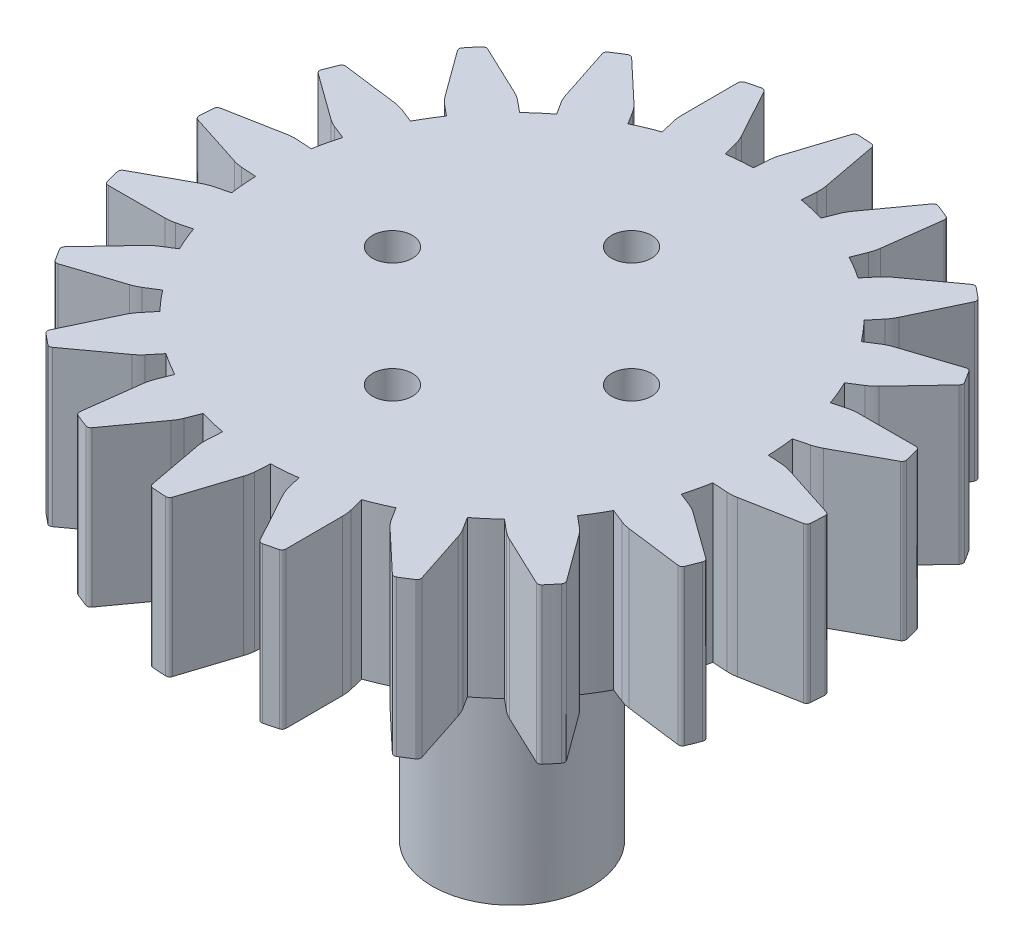
from build123d import *

# Parameters (mm, degrees)
SKETCH1_R           = 1.934028354
BOSS_EXTRUDE1_DEPTH = 7.8
SKETCH4_R           = 1
CUT_EXTRUDE1_DEPTH  = 10
SKETCH5_R           = 4
BOSS_EXTRUDE2_DEPTH = 15
SKETCH6_R           = 1.934028354
BOSS_EXTRUDE3_DEPTH = 20


with BuildPart() as part:
    # Sketch1 → Boss-Extrude1 (new body)
    with BuildSketch(Plane(origin=(0, 0, 0), x_dir=(1, 0, 0), z_dir=(0, 1, 0))):
        with BuildLine():
            Line((2.067271212, 12.648848174), (2.11435326, 13.397195901))
            ThreePointArc((2.11435326, 13.397195901), (2.11450544, 13.645915294), (2.083785622, 13.89273031))
            Line((2.083785622, 13.89273031), (1.557427029, 16.689164762))
            ThreePointArc((1.557427029, 16.689164762), (1.494636288, 16.800859841), (1.376943076, 16.8515232))
            ThreePointArc((1.376943076, 16.8515232), (1.030673751, 16.876365781), (0.684021261, 16.895118145))
            ThreePointArc((0.684021261, 16.895118145), (0.560906292, 16.859605153), (0.484611569, 16.756660589))
            Line((0.484611569, 16.756660589), (-0.388082701, 14.048247083))
            ThreePointArc((-0.388082701, 14.048247083), (-0.448161241, 13.822106517), (-0.481417178, 13.590496869))
            Line((-0.481417178, 13.590496869), (-0.528499226, 12.842149141))
            ThreePointArc((-0.528499226, 12.842149141), (-1.18702877, 12.804993072), (-1.842681652, 12.733152752))
            Line((-1.842681652, 12.733152752), (-2.029156128, 13.459422888))
            ThreePointArc((-2.029156128, 13.459422888), (-2.105869915, 13.696016113), (-2.211356233, 13.921258197))
            Line((-2.211356233, 13.921258197), (-3.576098772, 16.418171654))
            ThreePointArc((-3.576098772, 16.418171654), (-3.670331994, 16.504996582), (-3.797920728, 16.516811096))
            ThreePointArc((-3.797920728, 16.516811096), (-4.134919207, 16.433434689), (-4.470400115, 16.344147737))
            ThreePointArc((-4.470400115, 16.344147737), (-4.57651529, 16.272328257), (-4.617264264, 16.150845792))
            Line((-4.617264264, 16.150845792), (-4.610300035, 13.305314118))
            ThreePointArc((-4.610300035, 13.305314118), (-4.597556844, 13.071676369), (-4.557613802, 12.841125854))
            Line((-4.557613802, 12.841125854), (-4.371139325, 12.114855719))
            ThreePointArc((-4.371139325, 12.114855719), (-4.985956282, 11.876021376), (-5.587319349, 11.605089289))
            Line((-5.587319349, 11.605089289), (-5.989096929, 12.238189452))
            ThreePointArc((-5.989096929, 12.238189452), (-6.135167404, 12.439497117), (-6.305094485, 12.621118003))
            Line((-6.305094485, 12.621118003), (-8.374630462, 14.57409518))
            ThreePointArc((-8.374630462, 14.57409518), (-8.491081959, 14.627550926), (-8.616076943, 14.59936011))
            ThreePointArc((-8.616076943, 14.59936011), (-8.910816815, 14.415926177), (-9.202286933, 14.227339938))
            ThreePointArc((-9.202286933, 14.227339938), (-9.281015022, 14.126244161), (-9.282229453, 13.998115346))
            Line((-9.282229453, 13.998115346), (-8.396288432, 11.29400597))
            ThreePointArc((-8.396288432, 11.29400597), (-8.311970902, 11.075741129), (-8.202738785, 10.868817638))
            Line((-8.202738785, 10.868817638), (-7.800961204, 10.235717476))
            ThreePointArc((-7.800961204, 10.235717476), (-8.311883007, 9.81858363), (-8.800090651, 9.375080496))
            Line((-8.800090651, 9.375080496), (-9.377842546, 9.853038431))
            ThreePointArc((-9.377842546, 9.853038431), (-9.578971312, 9.999355138), (-9.796705511, 10.11957651))
            Line((-9.796705511, 10.11957651), (-12.368454324, 11.337446393))
            ThreePointArc((-12.368454324, 11.337446393), (-12.495725014, 11.352300337), (-12.605890866, 11.286863703))
            ThreePointArc((-12.605890866, 11.286863703), (-12.829520939, 11.021328037), (-13.048449142, 10.751902645))
            ThreePointArc((-13.048449142, 10.751902645), (-13.092083691, 10.63142653), (-13.053644702, 10.509193506))
            Line((-13.053644702, 10.509193506), (-11.375448969, 8.211203494))
            ThreePointArc((-11.375448969, 8.211203494), (-11.227810688, 8.029676845), (-11.059981896, 7.866635491))
            Line((-11.059981896, 7.866635491), (-10.48223, 7.388677556))
            ThreePointArc((-10.48223, 7.388677556), (-10.839244063, 6.834076175), (-11.166507118, 6.26141517))
            Line((-11.166507118, 6.26141517), (-11.863678947, 6.537445024))
            ThreePointArc((-11.863678947, 6.537445024), (-12.10017812, 6.614448276), (-12.344406096, 6.661502027))
            Line((-12.344406096, 6.661502027), (-15.166627054, 7.025051026))
            ThreePointArc((-15.166627054, 7.025051026), (-15.292258793, 6.999849161), (-15.376811713, 6.903572103))
            ThreePointArc((-15.376811713, 6.903572103), (-15.507441518, 6.581927184), (-15.632397587, 6.258035874))
            ThreePointArc((-15.632397587, 6.258035874), (-15.636667342, 6.129972464), (-15.562337609, 6.02560025))
            Line((-15.562337609, 6.02560025), (-13.256160656, 4.358672877))
            ThreePointArc((-13.256160656, 4.358672877), (-13.059653487, 4.231653512), (-12.849656271, 4.128453919))
            Line((-12.849656271, 4.128453919), (-12.152484442, 3.852424065))
            ThreePointArc((-12.152484442, 3.852424065), (-12.32064374, 3.214643394), (-12.454927419, 2.568880568))
            Line((-12.454927419, 2.568880568), (-13.203275146, 2.615962617))
            ThreePointArc((-13.203275146, 2.615962617), (-13.451994539, 2.616114797), (-13.698809555, 2.585394979))
            Line((-13.698809555, 2.585394979), (-16.495244007, 2.059036386))
            ThreePointArc((-16.495244007, 2.059036386), (-16.606939087, 1.996245645), (-16.657602445, 1.878552433))
            ThreePointArc((-16.657602445, 1.878552433), (-16.682445026, 1.532283107), (-16.701197391, 1.185630617))
            ThreePointArc((-16.701197391, 1.185630617), (-16.665684399, 1.062515649), (-16.562739835, 0.986220926))
            Line((-16.562739835, 0.986220926), (-13.854326328, 0.113526656))
            ThreePointArc((-13.854326328, 0.113526656), (-13.628185762, 0.053448116), (-13.396576114, 0.020192179))
            Line((-13.396576114, 0.020192179), (-12.648228387, -0.026889869))
            ThreePointArc((-12.648228387, -0.026889869), (-12.611072317, -0.685419413), (-12.539231998, -1.341072295))
            Line((-12.539231998, -1.341072295), (-13.265502133, -1.527546772))
            ThreePointArc((-13.265502133, -1.527546772), (-13.502095359, -1.604260559), (-13.727337442, -1.709746877))
            Line((-13.727337442, -1.709746877), (-16.2242509, -3.074489416))
            ThreePointArc((-16.2242509, -3.074489416), (-16.311075827, -3.168722637), (-16.322890342, -3.296311372))
            ThreePointArc((-16.322890342, -3.296311372), (-16.239513934, -3.63330985), (-16.150226982, -3.968790759))
            ThreePointArc((-16.150226982, -3.968790759), (-16.078407502, -4.074905934), (-15.956925038, -4.115654907))
            Line((-15.956925038, -4.115654907), (-13.111393363, -4.108690679))
            ThreePointArc((-13.111393363, -4.108690679), (-12.877755614, -4.095947487), (-12.6472051, -4.056004446))
            Line((-12.6472051, -4.056004446), (-11.920934964, -3.869529969))
            ThreePointArc((-11.920934964, -3.869529969), (-11.682100622, -4.484346926), (-11.411168535, -5.085709992))
            Line((-11.411168535, -5.085709992), (-12.044268697, -5.487487573))
            ThreePointArc((-12.044268697, -5.487487573), (-12.245576362, -5.633558047), (-12.427197249, -5.803485129))
            Line((-12.427197249, -5.803485129), (-14.380174426, -7.873021105))
            ThreePointArc((-14.380174426, -7.873021105), (-14.433630172, -7.989472603), (-14.405439355, -8.114467586))
            ThreePointArc((-14.405439355, -8.114467586), (-14.222005423, -8.409207458), (-14.033419183, -8.700677577))
            ThreePointArc((-14.033419183, -8.700677577), (-13.932323406, -8.779405665), (-13.804194592, -8.780620096))
            Line((-13.804194592, -8.780620096), (-11.100085215, -7.894679076))
            ThreePointArc((-11.100085215, -7.894679076), (-10.881820375, -7.810361546), (-10.674896884, -7.701129428))
            Line((-10.674896884, -7.701129428), (-10.041796721, -7.299351848))
            ThreePointArc((-10.041796721, -7.299351848), (-9.624662876, -7.81027365), (-9.181159741, -8.298481294))
            Line((-9.181159741, -8.298481294), (-9.659117676, -8.876233189))
            ThreePointArc((-9.659117676, -8.876233189), (-9.805434384, -9.077361956), (-9.925655755, -9.295096155))
            Line((-9.925655755, -9.295096155), (-11.143525638, -11.866844968))
            ThreePointArc((-11.143525638, -11.866844968), (-11.158379582, -11.994115657), (-11.092942949, -12.10428151))
            ThreePointArc((-11.092942949, -12.10428151), (-10.827407282, -12.327911583), (-10.55798189, -12.546839785))
            ThreePointArc((-10.55798189, -12.546839785), (-10.437505775, -12.590474334), (-10.315272751, -12.552035345))
            Line((-10.315272751, -12.552035345), (-8.01728274, -10.873839613))
            ThreePointArc((-8.01728274, -10.873839613), (-7.83575609, -10.726201331), (-7.672714737, -10.558372539))
            Line((-7.672714737, -10.558372539), (-7.194756802, -9.980620644))
            ThreePointArc((-7.194756802, -9.980620644), (-6.64015542, -10.337634706), (-6.067494416, -10.664897761))
            Line((-6.067494416, -10.664897761), (-6.34352427, -11.362069591))
            ThreePointArc((-6.34352427, -11.362069591), (-6.420527521, -11.598568764), (-6.467581272, -11.842796739))
            Line((-6.467581272, -11.842796739), (-6.831130272, -14.665017697))
            ThreePointArc((-6.831130272, -14.665017697), (-6.805928406, -14.790649437), (-6.709651349, -14.875202357))
            ThreePointArc((-6.709651349, -14.875202357), (-6.38800643, -15.005832162), (-6.06411512, -15.13078823))
            ThreePointArc((-6.06411512, -15.13078823), (-5.936051709, -15.135057986), (-5.831679496, -15.060728253))
            Line((-5.831679496, -15.060728253), (-4.164752122, -12.754551299))
            ThreePointArc((-4.164752122, -12.754551299), (-4.037732757, -12.55804413), (-3.934533164, -12.348046915))
            Line((-3.934533164, -12.348046915), (-3.65850331, -11.650875085))
            ThreePointArc((-3.65850331, -11.650875085), (-3.020722639, -11.819034384), (-2.374959814, -11.953318063))
            Line((-2.374959814, -11.953318063), (-2.422041862, -12.70166579))
            ThreePointArc((-2.422041862, -12.70166579), (-2.422194042, -12.950385182), (-2.391474224, -13.197200199))
            Line((-2.391474224, -13.197200199), (-1.865115631, -15.993634651))
            ThreePointArc((-1.865115631, -15.993634651), (-1.80232489, -16.10532973), (-1.684631678, -16.155993089))
            ThreePointArc((-1.684631678, -16.155993089), (-1.338362352, -16.18083567), (-0.991709863, -16.199588034))
            ThreePointArc((-0.991709863, -16.199588034), (-0.868594894, -16.164075042), (-0.792300171, -16.061130478))
            Line((-0.792300171, -16.061130478), (0.080394099, -13.352716972))
            ThreePointArc((0.080394099, -13.352716972), (0.140472639, -13.126576406), (0.173728576, -12.894966758))
            Line((0.173728576, -12.894966758), (0.220810624, -12.14661903))
            ThreePointArc((0.220810624, -12.14661903), (0.879340168, -12.109462961), (1.53499305, -12.037622641))
            Line((1.53499305, -12.037622641), (1.721467526, -12.763892777))
            ThreePointArc((1.721467526, -12.763892777), (1.798181314, -13.000486002), (1.903667631, -13.225728086))
            Line((1.903667631, -13.225728086), (3.26841017, -15.722641543))
            ThreePointArc((3.26841017, -15.722641543), (3.362643392, -15.809466471), (3.490232127, -15.821280985))
            ThreePointArc((3.490232127, -15.821280985), (3.827230605, -15.737904578), (4.162711513, -15.648617626))
            ThreePointArc((4.162711513, -15.648617626), (4.268826688, -15.576798146), (4.309575662, -15.455315681))
            Line((4.309575662, -15.455315681), (4.302611433, -12.609784007))
            ThreePointArc((4.302611433, -12.609784007), (4.289868242, -12.376146258), (4.2499252, -12.145595743))
            Line((4.2499252, -12.145595743), (4.063450724, -11.419325608))
            ThreePointArc((4.063450724, -11.419325608), (4.67826768, -11.180491265), (5.279630747, -10.909559178))
            Line((5.279630747, -10.909559178), (5.681408327, -11.542659341))
            ThreePointArc((5.681408327, -11.542659341), (5.827478802, -11.743967006), (5.997405883, -11.925587892))
            Line((5.997405883, -11.925587892), (8.06694186, -13.878565069))
            ThreePointArc((8.06694186, -13.878565069), (8.183393357, -13.932020815), (8.308388341, -13.903829999))
            ThreePointArc((8.308388341, -13.903829999), (8.603128213, -13.720396066), (8.894598331, -13.531809827))
            ThreePointArc((8.894598331, -13.531809827), (8.97332642, -13.43071405), (8.974540851, -13.302585235))
            Line((8.974540851, -13.302585235), (8.08859983, -10.598475859))
            ThreePointArc((8.08859983, -10.598475859), (8.0042823, -10.380211018), (7.895050183, -10.173287527))
            Line((7.895050183, -10.173287527), (7.493272603, -9.540187365))
            ThreePointArc((7.493272603, -9.540187365), (8.004194405, -9.123053519), (8.492402049, -8.679550385))
            Line((8.492402049, -8.679550385), (9.070153944, -9.15750832))
            ThreePointArc((9.070153944, -9.15750832), (9.27128271, -9.303825027), (9.489016909, -9.424046399))
            Line((9.489016909, -9.424046399), (12.060765723, -10.641916282))
            ThreePointArc((12.060765723, -10.641916282), (12.188036412, -10.656770226), (12.298202264, -10.591333592))
            ThreePointArc((12.298202264, -10.591333592), (12.521832337, -10.325797926), (12.74076054, -10.056372534))
            ThreePointArc((12.74076054, -10.056372534), (12.784395089, -9.935896419), (12.7459561, -9.813663395))
            Line((12.7459561, -9.813663395), (11.067760367, -7.515673383))
            ThreePointArc((11.067760367, -7.515673383), (10.920122086, -7.334146734), (10.752293294, -7.17110538))
            Line((10.752293294, -7.17110538), (10.174541398, -6.693147445))
            ThreePointArc((10.174541398, -6.693147445), (10.531555461, -6.138546064), (10.858818516, -5.565885059))
            Line((10.858818516, -5.565885059), (11.555990345, -5.841914913))
            ThreePointArc((11.555990345, -5.841914913), (11.792489518, -5.918918165), (12.036717494, -5.965971916))
            Line((12.036717494, -5.965971916), (14.858938452, -6.329520915))
            ThreePointArc((14.858938452, -6.329520915), (14.984570191, -6.30431905), (15.069123111, -6.208041992))
            ThreePointArc((15.069123111, -6.208041992), (15.199752916, -5.886397073), (15.324708985, -5.562505763))
            ThreePointArc((15.324708985, -5.562505763), (15.32897874, -5.434442352), (15.254649008, -5.330070139))
            Line((15.254649008, -5.330070139), (12.948472054, -3.663142765))
            ThreePointArc((12.948472054, -3.663142765), (12.751964885, -3.536123401), (12.541967669, -3.432923808))
            Line((12.541967669, -3.432923808), (11.84479584, -3.156893954))
            ThreePointArc((11.84479584, -3.156893954), (12.012955138, -2.519113283), (12.147238817, -1.873350457))
            Line((12.147238817, -1.873350457), (12.895586544, -1.920432506))
            ThreePointArc((12.895586544, -1.920432506), (13.144305937, -1.920584686), (13.391120953, -1.889864868))
            Line((13.391120953, -1.889864868), (16.187555405, -1.363506275))
            ThreePointArc((16.187555405, -1.363506275), (16.299250485, -1.300715534), (16.349913843, -1.183022322))
            ThreePointArc((16.349913843, -1.183022322), (16.374756425, -0.836752996), (16.393508789, -0.490100506))
            ThreePointArc((16.393508789, -0.490100506), (16.357995797, -0.366985538), (16.255051233, -0.290690815))
            Line((16.255051233, -0.290690815), (13.546637726, 0.582003455))
            ThreePointArc((13.546637726, 0.582003455), (13.32049716, 0.642081995), (13.088887512, 0.675337932))
            Line((13.088887512, 0.675337932), (12.340539785, 0.72241998))
            ThreePointArc((12.340539785, 0.72241998), (12.303383716, 1.380949524), (12.231543396, 2.036602406))
            Line((12.231543396, 2.036602406), (12.957813531, 2.223076883))
            ThreePointArc((12.957813531, 2.223076883), (13.194406757, 2.29979067), (13.419648841, 2.405276988))
            Line((13.419648841, 2.405276988), (15.916562298, 3.770019527))
            ThreePointArc((15.916562298, 3.770019527), (16.003387225, 3.864252748), (16.01520174, 3.991841483))
            ThreePointArc((16.01520174, 3.991841483), (15.931825332, 4.328839961), (15.84253838, 4.66432087))
            ThreePointArc((15.84253838, 4.66432087), (15.7707189, 4.770436045), (15.649236436, 4.811185019))
            Line((15.649236436, 4.811185019), (12.803704761, 4.80422079))
            ThreePointArc((12.803704761, 4.80422079), (12.570067013, 4.791477598), (12.339516498, 4.751534557))
            Line((12.339516498, 4.751534557), (11.613246362, 4.56506008))
            ThreePointArc((11.613246362, 4.56506008), (11.37441202, 5.179877037), (11.103479933, 5.781240103))
            Line((11.103479933, 5.781240103), (11.736580095, 6.183017684))
            ThreePointArc((11.736580095, 6.183017684), (11.93788776, 6.329088158), (12.119508647, 6.49901524))
            Line((12.119508647, 6.49901524), (14.072485824, 8.568551216))
            ThreePointArc((14.072485824, 8.568551216), (14.12594157, 8.685002714), (14.097750754, 8.809997697))
            ThreePointArc((14.097750754, 8.809997697), (13.914316821, 9.104737569), (13.725730581, 9.396207688))
            ThreePointArc((13.725730581, 9.396207688), (13.624634805, 9.474935777), (13.49650599, 9.476150207))
            Line((13.49650599, 9.476150207), (10.792396613, 8.590209187))
            ThreePointArc((10.792396613, 8.590209187), (10.574131773, 8.505891657), (10.367208282, 8.396659539))
            Line((10.367208282, 8.396659539), (9.734108119, 7.994881959))
            ThreePointArc((9.734108119, 7.994881959), (9.316974274, 8.505803761), (8.873471139, 8.994011405))
            Line((8.873471139, 8.994011405), (9.351429074, 9.571763301))
            ThreePointArc((9.351429074, 9.571763301), (9.497745782, 9.772892067), (9.617967153, 9.990626266))
            Line((9.617967153, 9.990626266), (10.835837036, 12.562375079))
            ThreePointArc((10.835837036, 12.562375079), (10.85069098, 12.689645768), (10.785254347, 12.799811621))
            ThreePointArc((10.785254347, 12.799811621), (10.51971868, 13.023441694), (10.250293288, 13.242369897))
            ThreePointArc((10.250293288, 13.242369897), (10.129817174, 13.286004445), (10.00758415, 13.247565456))
            Line((10.00758415, 13.247565456), (7.709594138, 11.569369724))
            ThreePointArc((7.709594138, 11.569369724), (7.528067488, 11.421731442), (7.365026135, 11.25390265))
            Line((7.365026135, 11.25390265), (6.8870682, 10.676150755))
            ThreePointArc((6.8870682, 10.676150755), (6.332466818, 11.033164817), (5.759805814, 11.360427873))
            Line((5.759805814, 11.360427873), (6.035835668, 12.057599702))
            ThreePointArc((6.035835668, 12.057599702), (6.112838919, 12.294098875), (6.15989267, 12.53832685))
            Line((6.15989267, 12.53832685), (6.52344167, 15.360547808))
            ThreePointArc((6.52344167, 15.360547808), (6.498239804, 15.486179548), (6.401962747, 15.570732468))
            ThreePointArc((6.401962747, 15.570732468), (6.080317828, 15.701362273), (5.756426518, 15.826318341))
            ThreePointArc((5.756426518, 15.826318341), (5.628363107, 15.830588097), (5.523990894, 15.756258364))
            Line((5.523990894, 15.756258364), (3.85706352, 13.45008141))
            ThreePointArc((3.85706352, 13.45008141), (3.730044155, 13.253574241), (3.626844562, 13.043577026))
            Line((3.626844562, 13.043577026), (3.350814708, 12.346405196))
            ThreePointArc((3.350814708, 12.346405196), (2.713034038, 12.514564495), (2.067271212, 12.648848174))
        make_face()
        with Locations((-0.153844301, 0.347765056)):
            Circle(SKETCH1_R, mode=Mode.SUBTRACT)
    extrude(amount=BOSS_EXTRUDE1_DEPTH)

    # Sketch4 → Cut-Extrude1 (cut)
    with BuildSketch(Plane(origin=(0, 7.8, 0), x_dir=(1, 0, 0), z_dir=(0, 1, 0))):
        with Locations((-0.153844301, 6.347765056)):
            Circle(SKETCH4_R)
        with Locations((-0.153844301, -5.652234944)):
            Circle(SKETCH4_R)
        with Locations((5.846155699, 0.347765056)):
            Circle(SKETCH4_R)
        with Locations((-6.153844301, 0.347765056)):
            Circle(SKETCH4_R)
    extrude(amount=-CUT_EXTRUDE1_DEPTH, mode=Mode.SUBTRACT)

    # Sketch5 → Boss-Extrude2 (add)
    with BuildSketch(Plane.XZ):
        with Locations((-0.153844301, -0.347765056)):
            Circle(SKETCH5_R)
    extrude(amount=BOSS_EXTRUDE2_DEPTH)

    # Sketch6 → Boss-Extrude3 (add)
    with BuildSketch(Plane(origin=(0, 7.8, 0), x_dir=(1, 0, 0), z_dir=(0, 1, 0))):
        with Locations((-0.153844301, 0.347765056)):
            Circle(SKETCH6_R)
    extrude(amount=-BOSS_EXTRUDE3_DEPTH)


solid = part.part
